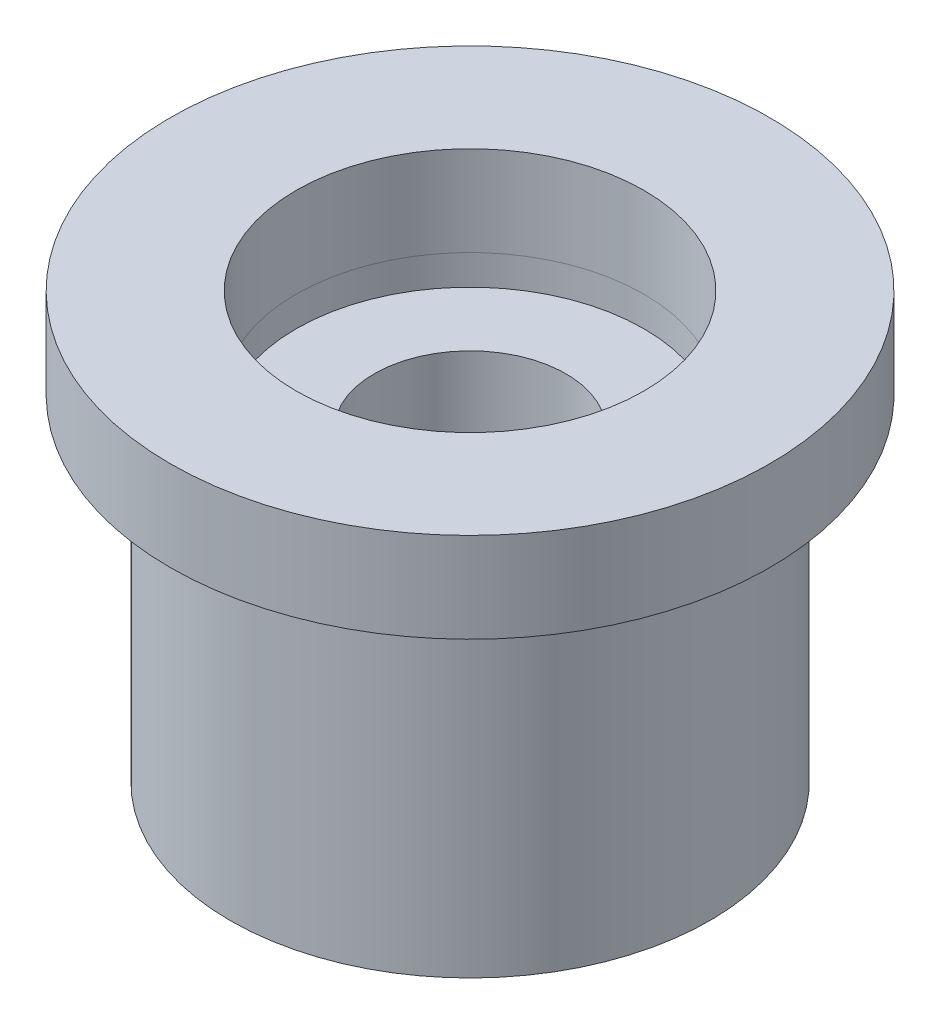
from build123d import *

# Parameters (mm, degrees)
CROQUIS2_R              = 4
SALIENTE_EXTRUIR2_DEPTH = 5.6
CROQUIS3_R              = 5
SALIENTE_EXTRUIR3_DEPTH = 1.5
CROQUIS4_R              = 2.9
CORTAR_EXTRUIR2_DEPTH   = 2
CROQUIS6_R              = 1.6
CORTAR_EXTRUIR3_DEPTH   = 6.1
CORTAR_EXTRUIR4_DEPTH   = 4.3


with BuildPart() as part:
    # Croquis2 → Saliente-Extruir2 (new body)
    with BuildSketch(Plane(origin=(0, 0, 0), x_dir=(1, 0, 0), z_dir=(0, 1, 0))):
        Circle(CROQUIS2_R)
    extrude(amount=SALIENTE_EXTRUIR2_DEPTH)


with BuildPart() as body_2:
    # Croquis3 → Saliente-Extruir3 (new body)
    with BuildSketch(Plane(origin=(0, 5.6, 0), x_dir=(1, 0, 0), z_dir=(0, 1, 0))):
        Circle(CROQUIS3_R)
    extrude(amount=SALIENTE_EXTRUIR3_DEPTH)


with BuildPart() as cortar_extruir2_tool:
    # Croquis4 → Cortar-Extruir2 (new body)
    with BuildSketch(Plane(origin=(0, 7.1, 0), x_dir=(1, 0, 0), z_dir=(0, 1, 0))):
        Circle(CROQUIS4_R)
    extrude(amount=-CORTAR_EXTRUIR2_DEPTH)


with BuildPart() as part_1:
    add(part.part)

    # Cortar-Extruir2: cut by cortar_extruir2_tool
    add(cortar_extruir2_tool.part, mode=Mode.SUBTRACT)

    # Croquis6 → Cortar-Extruir3 (cut, through all)
    with BuildSketch(Plane(origin=(0, 5.1, 0), x_dir=(1, 0, 0), z_dir=(0, 1, 0))):
        Circle(CROQUIS6_R)
    extrude(amount=-CORTAR_EXTRUIR3_DEPTH, mode=Mode.SUBTRACT)

    # Croquis7 → Cortar-Extruir4 (cut)
    with BuildSketch(Plane.XZ):
        with BuildLine():
            Line((2.264950331, 0.4), (3.07408523, 0.4))
            ThreePointArc((3.07408523, 0.4), (1.55, 2.684678752), (-1.190632453, 2.862235902))
            Line((-1.190632453, 2.862235902), (-0.786065004, 2.161504525))
            ThreePointArc((-0.786065004, 2.161504525), (1.15, 1.991858429), (2.264950331, 0.4))
        make_face()
        with BuildLine():
            Line((2.264950331, -0.4), (3.07408523, -0.4))
            ThreePointArc((3.07408523, -0.4), (1.55, -2.684678752), (-1.190632453, -2.862235902))
            Line((-1.190632453, -2.862235902), (-0.786065004, -2.161504525))
            ThreePointArc((-0.786065004, -2.161504525), (1.15, -1.991858429), (2.264950331, -0.4))
        make_face()
        with BuildLine():
            Line((-1.478885327, -1.761504525), (-1.883452776, -2.462235902))
            ThreePointArc((-1.883452776, -2.462235902), (-3.1, 0), (-1.883452776, 2.462235902))
            Line((-1.883452776, 2.462235902), (-1.478885327, 1.761504525))
            ThreePointArc((-1.478885327, 1.761504525), (-2.3, 0), (-1.478885327, -1.761504525))
        make_face()
    extrude(amount=-CORTAR_EXTRUIR4_DEPTH, mode=Mode.SUBTRACT)


with BuildPart() as body_2_1:
    add(body_2.part)

    # Cortar-Extruir2: cut by cortar_extruir2_tool
    add(cortar_extruir2_tool.part, mode=Mode.SUBTRACT)


solid = Compound([part_1.part, body_2_1.part])
